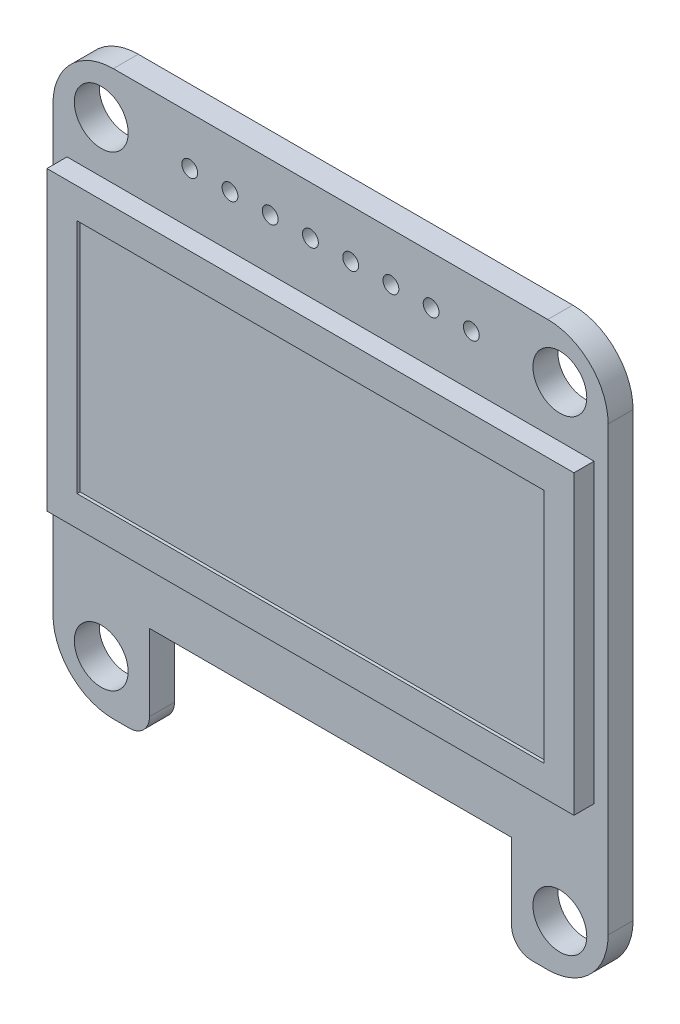
from build123d import *

# Parameters (mm, degrees)
SKETCH2_W                = 35.052
SKETCH2_H                = 35.56
BOSS_EXTRUDE1_DEPTH      = 1.5748
CUT_EXTRUDE4_START       = 1.5748
SKETCH2_8_W              = 22.86
SKETCH2_8_H              = 6.096
CUT_EXTRUDE4_DEPTH       = 1.5748
M3_CLEARANCE_HOLE1_D     = 3.4
F_1_0_1_DIAMETER_HOLE1_D = 1
FILLET2_R                = 3.81
FILLET3_R                = 1.27
SKETCH10_W               = 33.274
SKETCH10_H               = 18.731056846
BOSS_EXTRUDE2_DEPTH      = 1.27
SKETCH11_W               = 29.464
SKETCH11_H               = 14.921056846
CUT_EXTRUDE5_DEPTH       = 0.1905


with BuildPart() as part:
    # Sketch2 → Boss-Extrude1 (new body)
    with BuildSketch(Plane.XY):
        with Locations((14.478, 14.732)):
            Rectangle(SKETCH2_W, SKETCH2_H)
    extrude(amount=BOSS_EXTRUDE1_DEPTH)

    # Sketch2_8 → Cut-Extrude4 (cut)
    with BuildSketch(Plane.XY.offset(CUT_EXTRUDE4_START)):
        with Locations((14.478, 0)):
            Rectangle(SKETCH2_8_W, SKETCH2_8_H)
    extrude(amount=-CUT_EXTRUDE4_DEPTH, mode=Mode.SUBTRACT)

    # M3 Clearance Hole1 (through all)
    with Locations(Plane.XY.offset(1.5748)):
        with Locations((0, 29.464), (0, 0), (28.956, 0), (28.956, 29.464)):
            Hole(M3_CLEARANCE_HOLE1_D / 2)

    # Ø1.0 (1) Diameter Hole1 (through all)
    with Locations(Plane.XY.offset(1.5748)):
        with Locations((5.588, 29.464), (8.128, 29.464), (10.668, 29.464), (13.208, 29.464), (15.748, 29.464), (18.288, 29.464), (20.828, 29.464), (23.368, 29.464)):
            Hole(F_1_0_1_DIAMETER_HOLE1_D / 2)

    # Fillet2
    fillet2_edges = [part.edges().sort_by_distance(p)[0] for p in [
        (-3.048, 32.512, 0.7874),
        (-3.048, -3.048, 0.7874),
        (32.004, -3.048, 0.7874),
        (32.004, 32.512, 0.7874),
    ]]
    fillet(fillet2_edges, radius=FILLET2_R)

    # Fillet3
    fillet3_edges = [part.edges().sort_by_distance(p)[0] for p in [
        (25.908, -3.048, 0.7874),
        (3.048, -3.048, 0.7874),
    ]]
    fillet(fillet3_edges, radius=FILLET3_R)

    # Sketch10 → Boss-Extrude2 (add)
    with BuildSketch(Plane.XY.offset(1.5748)):
        with Locations((14.478, 16.858528423)):
            Rectangle(SKETCH10_W, SKETCH10_H)
    extrude(amount=BOSS_EXTRUDE2_DEPTH)

    # Sketch11 → Cut-Extrude5 (cut)
    with BuildSketch(Plane.XY.offset(2.8448)):
        with Locations((14.478, 16.858528423)):
            Rectangle(SKETCH11_W, SKETCH11_H)
    extrude(amount=-CUT_EXTRUDE5_DEPTH, mode=Mode.SUBTRACT)


solid = part.part
